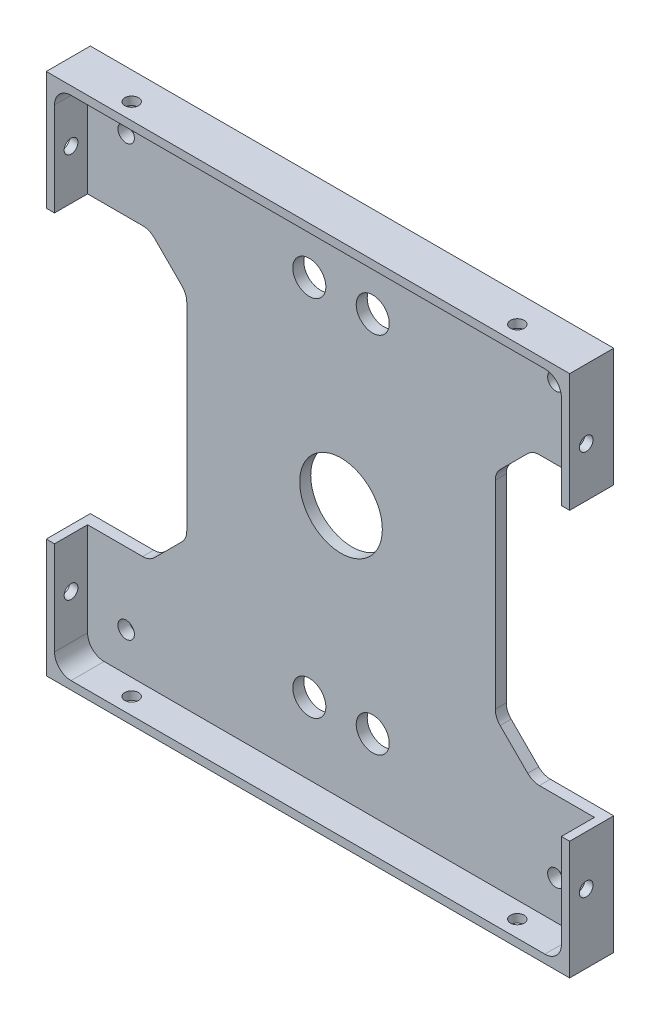
from build123d import *

# Parameters (mm, degrees)
SKETCH1_W                       = 96
SKETCH1_H                       = 96
BOSS_EXTRUDE1_DEPTH             = 8
SKETCH2_W                       = 92
SKETCH2_H                       = 92
COMPONENT_PLATFORM_DEPTH        = 6
CABLE_SLOTS_DEPTH               = 6
SKETCH4_R                       = 7.5
CENTER_MASS_CUT_DEPTH           = 6
INNER_CORNER_FILLETS_R          = 3
TAP_DRILL_FOR_M3X0_5_TAP1_D     = 2.5
TAP_DRILL_FOR_M3X0_5_TAP1_DEPTH = 2
TAP_DRILL_FOR_M3X0_5_TAP2_D     = 2.5
TAP_DRILL_FOR_M3X0_5_TAP2_DEPTH = 2
F_3_0MM_DOWEL_HOLE3_D           = 3
F_3_0MM_DOWEL_HOLE3_DEPTH       = 10
F_3_0MM_DOWEL_HOLE3_TIP         = 0.901290929
CUT_EXTRUDE1_START              = -8
SKETCH16_OUTSIDE_W              = 125.2
SKETCH16_OUTSIDE_H              = 125.2
SKETCH16_OUTSIDE_W_2            = 95
SKETCH16_OUTSIDE_H_2            = 95
CUT_EXTRUDE1_DEPTH              = 8
SKETCH17_R                      = 3
CUT_EXTRUDE3_DEPTH              = 9


with BuildPart() as part:
    # Sketch1 → Boss-Extrude1 (new body)
    with BuildSketch(Plane.XY):
        Rectangle(SKETCH1_W, SKETCH1_H)
    extrude(amount=BOSS_EXTRUDE1_DEPTH)

    # Sketch2 → Component Platform (cut)
    with BuildSketch(Plane.XY.offset(8)):
        Rectangle(SKETCH2_W, SKETCH2_H)
    extrude(amount=-COMPONENT_PLATFORM_DEPTH, mode=Mode.SUBTRACT)

    # Sketch3 → Cable Slots (cut, symmetric)
    with BuildSketch(Plane.XY.offset(2)):
        with BuildLine():
            Line((-33.878679656, -25.121320344), (-28.878679656, -20.121320344))
            ThreePointArc((-28.878679656, -20.121320344), (-28.228361402, -19.148050297), (-28, -18))
            Line((-28, -18), (-28, 18))
            ThreePointArc((-28, 18), (-28.228361402, 19.148050297), (-28.878679656, 20.121320344))
            Line((-28.878679656, 20.121320344), (-33.878679656, 25.121320344))
            ThreePointArc((-33.878679656, 25.121320344), (-34.851949703, 25.771638598), (-36, 26))
            Line((-36, 26), (-48, 26))
            Line((-48, 26), (-48, -26))
            Line((-48, -26), (-36, -26))
            ThreePointArc((-36, -26), (-34.851949703, -25.771638598), (-33.878679656, -25.121320344))
        make_face()
        with BuildLine():
            Line((48, -26), (48, 26))
            Line((48, 26), (36, 26))
            ThreePointArc((36, 26), (34.851949703, 25.771638598), (33.878679656, 25.121320344))
            Line((33.878679656, 25.121320344), (28.878679656, 20.121320344))
            ThreePointArc((28.878679656, 20.121320344), (28.228361402, 19.148050297), (28, 18))
            Line((28, 18), (28, -18))
            ThreePointArc((28, -18), (28.228361402, -19.148050297), (28.878679656, -20.121320344))
            Line((28.878679656, -20.121320344), (33.878679656, -25.121320344))
            ThreePointArc((33.878679656, -25.121320344), (34.851949703, -25.771638598), (36, -26))
            Line((36, -26), (48, -26))
        make_face()
    extrude(amount=CABLE_SLOTS_DEPTH, both=True, mode=Mode.SUBTRACT)

    # Sketch4 → Center Mass Cut (cut)
    with BuildSketch(Plane.XY.offset(2)):
        Circle(SKETCH4_R)
    extrude(amount=-CENTER_MASS_CUT_DEPTH, mode=Mode.SUBTRACT)

    # Inner Corner Fillets
    inner_corner_fillets_edges = [part.edges().sort_by_distance(p)[0] for p in [
        (-46, -46, 5),
        (-46, 46, 5),
        (46, 46, 5),
        (46, -46, 5),
    ]]
    fillet(inner_corner_fillets_edges, radius=INNER_CORNER_FILLETS_R)

    # Tap Drill for M3x0.5 Tap1
    with Locations(Plane(origin=(0, -48, 0), x_dir=(-1, 0, 0), z_dir=(0, -1, 0))):
        with Locations((35, -5), (-35, -5)):
            tap_drill_for_m3x0_5_tap1 = Hole(TAP_DRILL_FOR_M3X0_5_TAP1_D / 2, depth=TAP_DRILL_FOR_M3X0_5_TAP1_DEPTH)

    # Tap Drill for M3x0.5 Tap2
    with Locations(Plane(origin=(48, 0, 0), x_dir=(0, 0, -1), z_dir=(1, 0, 0))):
        with Locations((-5, -35), (-5, 35)):
            tap_drill_for_m3x0_5_tap2 = Hole(TAP_DRILL_FOR_M3X0_5_TAP2_D / 2, depth=TAP_DRILL_FOR_M3X0_5_TAP2_DEPTH)

    # Mirror1: Tap Drill for M3x0.5 Tap1 across plane
    add(tap_drill_for_m3x0_5_tap1.mirror(Plane(origin=(0, 0, 0), x_dir=(0, 0, 1), z_dir=(0, -1, 0))), mode=Mode.SUBTRACT)

    # Mirror2: Tap Drill for M3x0.5 Tap2 across plane
    add(tap_drill_for_m3x0_5_tap2.mirror(Plane(origin=(0, 0, 0), x_dir=(0, 0, 1), z_dir=(1, 0, 0))), mode=Mode.SUBTRACT)

    # Ø3.0mm Dowel Hole3
    with Locations(Plane.XY.offset(2)):
        with Locations((-39, -39), (39, -39), (39, 39), (-39, 39)):
            Hole(F_3_0MM_DOWEL_HOLE3_D / 2, depth=F_3_0MM_DOWEL_HOLE3_DEPTH)
            with Locations((0, 0, -(F_3_0MM_DOWEL_HOLE3_DEPTH + F_3_0MM_DOWEL_HOLE3_TIP / 2))):  # 118° drill point
                Cone(0, F_3_0MM_DOWEL_HOLE3_D / 2, F_3_0MM_DOWEL_HOLE3_TIP, mode=Mode.SUBTRACT)

    # Sketch16 outside → Cut-Extrude1 (cut)
    with BuildSketch(Plane(origin=(0, 0, 0), x_dir=(-1, 0, 0), z_dir=(0, 0, -1)).offset(CUT_EXTRUDE1_START)):
        Rectangle(SKETCH16_OUTSIDE_W, SKETCH16_OUTSIDE_H)
        Rectangle(SKETCH16_OUTSIDE_W_2, SKETCH16_OUTSIDE_H_2, mode=Mode.SUBTRACT)
    extrude(amount=CUT_EXTRUDE1_DEPTH, mode=Mode.SUBTRACT)

    # Sketch17 → Cut-Extrude3 (cut, through all)
    with BuildSketch(Plane(origin=(0, 0, 0), x_dir=(-1, 0, 0), z_dir=(0, 0, -1))):
        with Locations((-5.755, -32.99999626)):
            Circle(SKETCH17_R)
        with Locations((5.755, -32.99999626)):
            Circle(SKETCH17_R)
    cut_extrude3 = extrude(amount=-CUT_EXTRUDE3_DEPTH, mode=Mode.SUBTRACT)

    # Mirror4: Cut-Extrude3 across plane
    add(cut_extrude3.mirror(Plane(origin=(0, 0, 0), x_dir=(0, 0, 1), z_dir=(0, -1, 0))), mode=Mode.SUBTRACT)


solid = part.part
